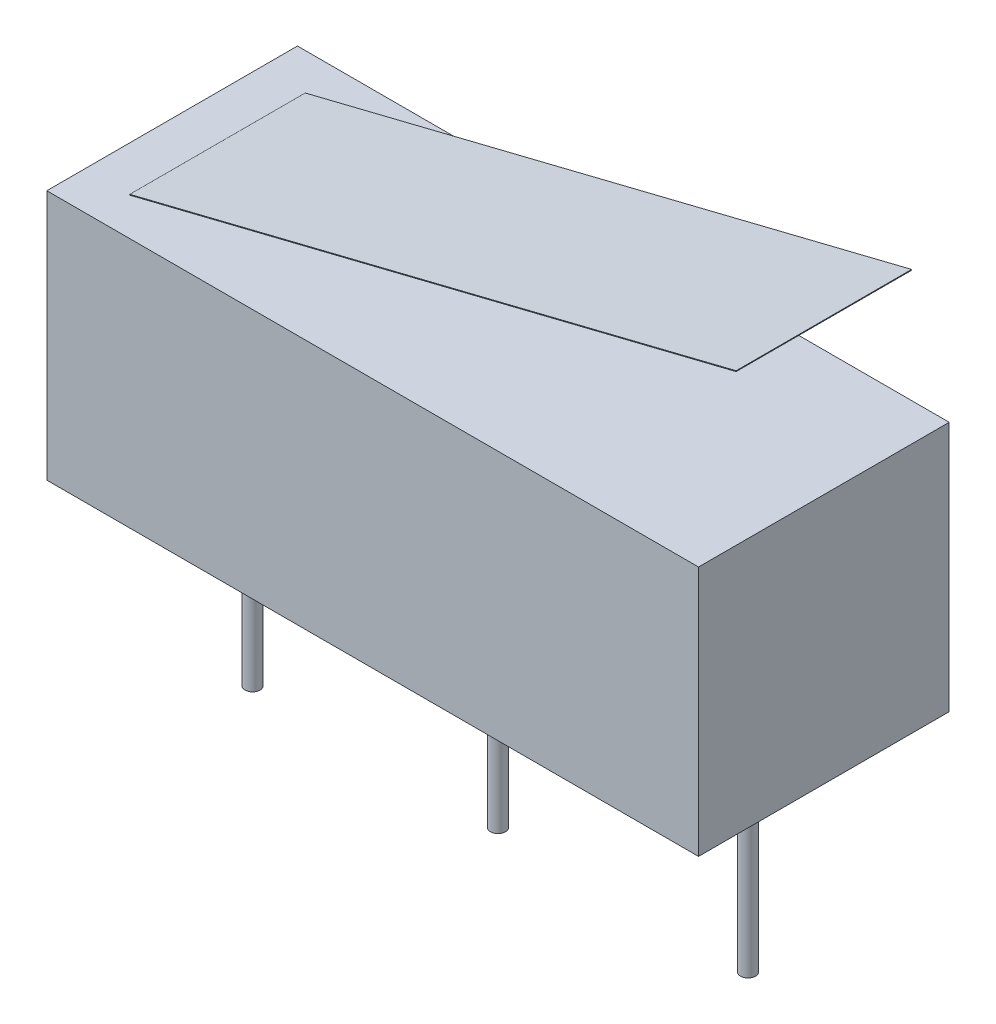
from build123d import *

# Parameters (mm, degrees)
SALIENTE_EXTRUIR1_START = 1
CROQUIS1_W              = 13
CROQUIS1_H              = 5
SALIENTE_EXTRUIR1_DEPTH = 5
CROQUIS2_R              = 0.15
SALIENTE_EXTRUIR2_DEPTH = 4
SALIENTE_EXTRUIR3_START = -0.75
SALIENTE_EXTRUIR3_DEPTH = 3.5


with BuildPart() as part:
    # Croquis1 → Saliente-Extruir1 (new body)
    with BuildSketch(Plane(origin=(0, 0, 0), x_dir=(1, 0, 0), z_dir=(0, 1, 0)).offset(SALIENTE_EXTRUIR1_START)):
        Rectangle(CROQUIS1_W, CROQUIS1_H)
    extrude(amount=SALIENTE_EXTRUIR1_DEPTH)

    # Croquis2 → Saliente-Extruir2 (add)
    with BuildSketch(Plane.XZ.offset(-1)):
        Circle(CROQUIS2_R)
        with Locations((-4.896514092, 0)):
            Circle(CROQUIS2_R)
        with Locations((4.98803772, 0)):
            Circle(CROQUIS2_R)
    extrude(amount=SALIENTE_EXTRUIR2_DEPTH)


with BuildPart() as body_2:
    # Croquis3 → Saliente-Extruir3 (new body)
    with BuildSketch(Plane.XY.offset(2.5).offset(SALIENTE_EXTRUIR3_START)):
        Polygon((-5.596201579, 6), (6.5, 9), (6.5, 9.015531113), (-5.596201579, 6.015531113), align=None)
    extrude(amount=-SALIENTE_EXTRUIR3_DEPTH)


solid = Compound([part.part, body_2.part])
